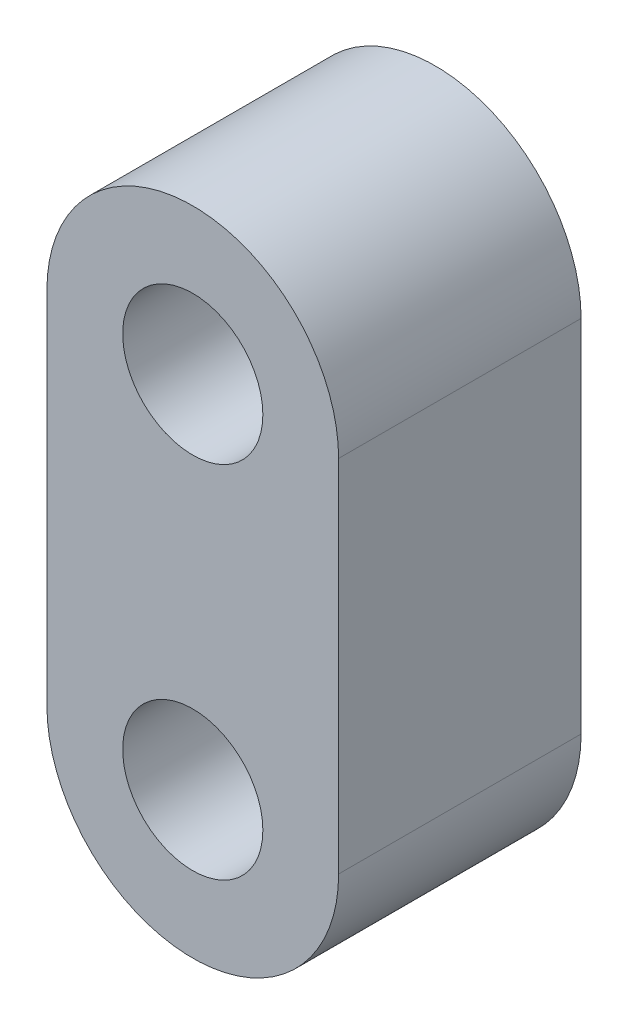
from build123d import *

# Parameters (mm, degrees)
CROQUIS1_R              = 1.85
SALIENTE_EXTRUIR1_DEPTH = 6.4


with BuildPart() as part:
    # Croquis1 → Saliente-Extruir1 (new body)
    with BuildSketch(Plane.XY):
        with BuildLine():
            Line((3.85, 0), (3.85, -9.5))
            ThreePointArc((3.85, -9.5), (0, -13.35), (-3.85, -9.5))
            Line((-3.85, -9.5), (-3.85, 0))
            ThreePointArc((-3.85, 0), (0, 3.85), (3.85, 0))
        make_face()
        Circle(CROQUIS1_R, mode=Mode.SUBTRACT)
        with Locations((0, -9.5)):
            Circle(CROQUIS1_R, mode=Mode.SUBTRACT)
    extrude(amount=SALIENTE_EXTRUIR1_DEPTH)


solid = part.part
